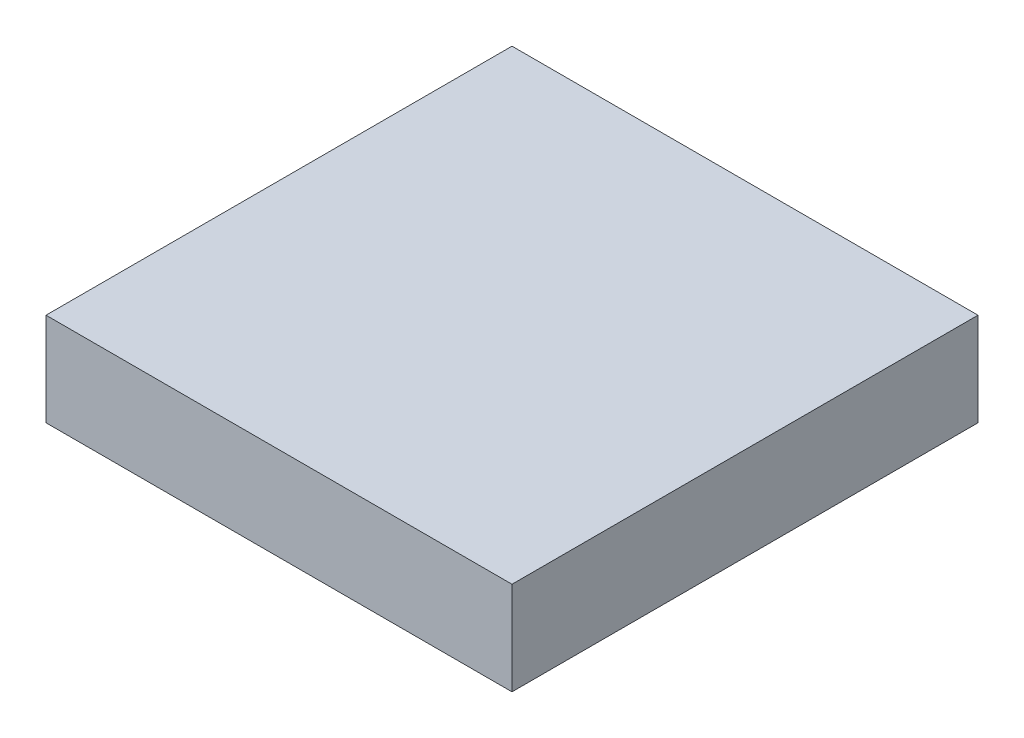
from build123d import *

# Parameters (mm, degrees)
SKETCH1_W           = 25400
SKETCH1_H           = 25400
BOSS_EXTRUDE1_DEPTH = 5080


with BuildPart() as part:
    # Sketch1 → Boss-Extrude1 (new body)
    with BuildSketch(Plane(origin=(0, 0, 0), x_dir=(1, 0, 0), z_dir=(0, 1, 0))):
        with Locations((12700, 12700)):
            Rectangle(SKETCH1_W, SKETCH1_H)
    extrude(amount=BOSS_EXTRUDE1_DEPTH)


solid = part.part
